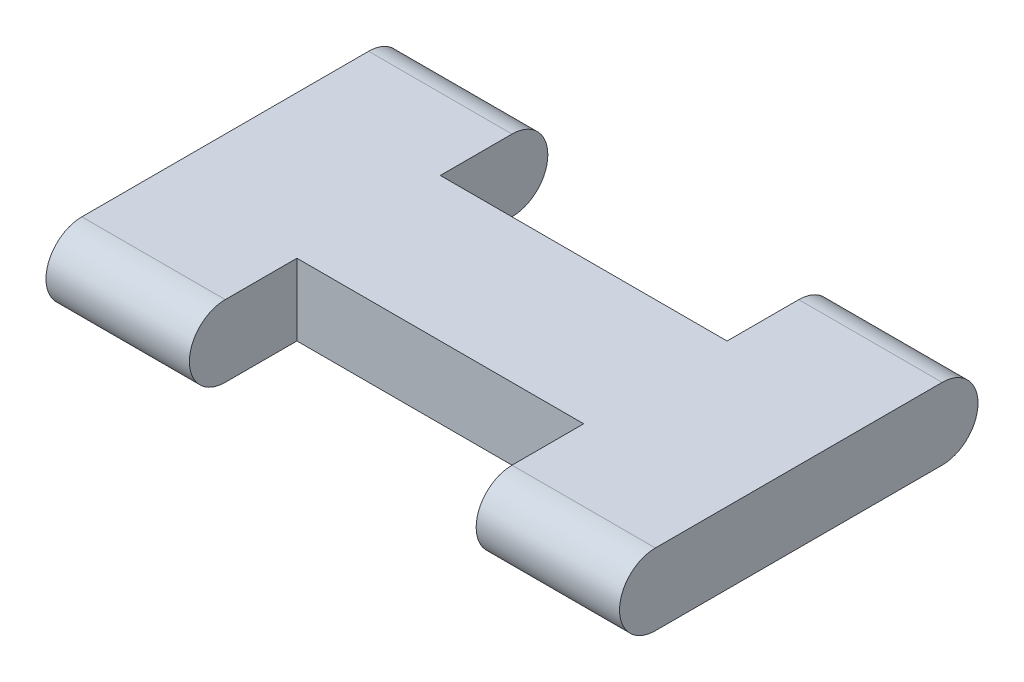
from build123d import *

# Parameters (mm, degrees)
EXTRUDE_1_DEPTH     = 16
SKETCH_2_W          = 8
SKETCH_2_H          = 9.708819165
SKETCH_2_H_2        = 9.650339741
CUT_EXTRUDE_1_DEPTH = 14


with BuildPart() as part:
    # 草图1 → 凸台-拉伸1 (new body)
    with BuildSketch(Plane(origin=(0, 0, 0), x_dir=(0, 0, -1), z_dir=(1, 0, 0))):
        with BuildLine():
            Line((-4, 1), (4, 1))
            ThreePointArc((4, 1), (5, 0), (4, -1))
            Line((4, -1), (-4, -1))
            ThreePointArc((-4, -1), (-5, 0), (-4, 1))
        make_face()
    extrude(amount=EXTRUDE_1_DEPTH)

    # 草图2 → 切除-拉伸1 (cut)
    with BuildSketch(Plane(origin=(0, 1, 0), x_dir=(1, 0, 0), z_dir=(0, 1, 0))):
        with Locations((8, 6.854409583)):
            Rectangle(SKETCH_2_W, SKETCH_2_H)
        with Locations((8, -6.825169871)):
            Rectangle(SKETCH_2_W, SKETCH_2_H_2)
    extrude(amount=-CUT_EXTRUDE_1_DEPTH, mode=Mode.SUBTRACT)


solid = part.part
